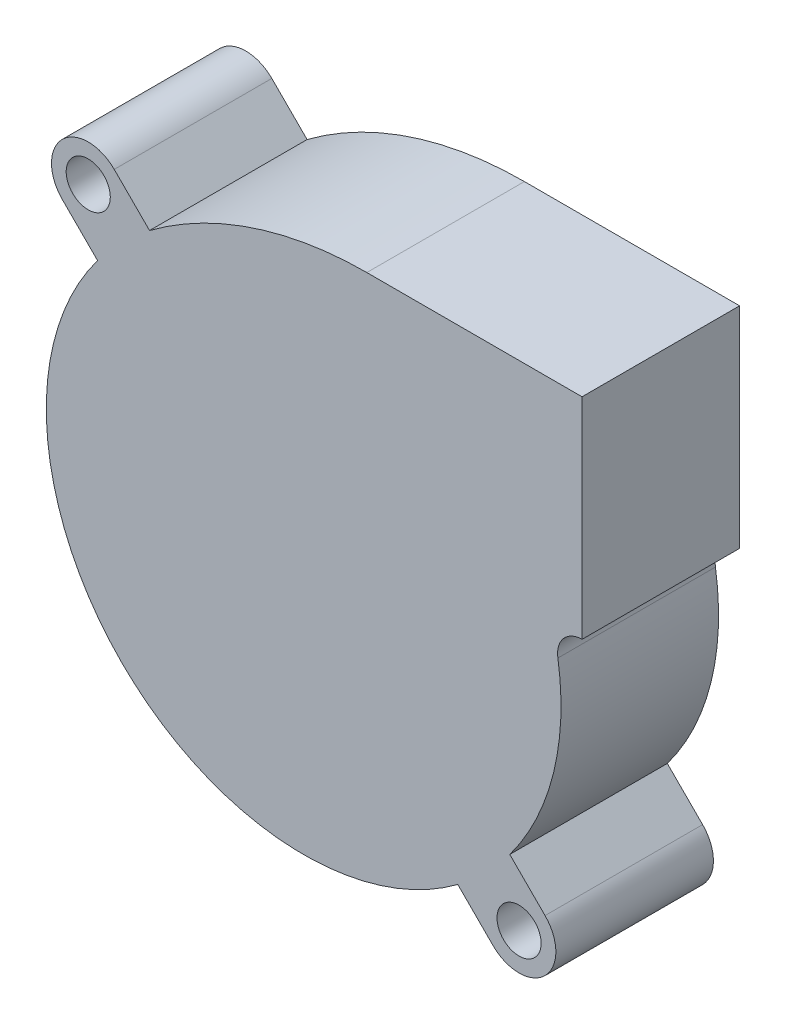
from build123d import *

# Parameters (mm, degrees)
SKETCH1_R           = 2.1
BOSS_EXTRUDE1_DEPTH = 15


with BuildPart() as part:
    # Sketch1 → Boss-Extrude1 (new body)
    with BuildSketch(Plane.XY):
        with BuildLine():
            Line((-22.980970389, 18.03122292), (-19.621301934, 14.671554465))
            ThreePointArc((-19.621301934, 14.671554465), (-17.324116139, -17.324116139), (14.671554465, -19.621301934))
            Line((14.671554465, -19.621301934), (18.03122292, -22.980970389))
            ThreePointArc((18.03122292, -22.980970389), (22.980970389, -22.980970389), (22.980970389, -18.03122292))
            Line((22.980970389, -18.03122292), (19.621301934, -14.671554465))
            ThreePointArc((19.621301934, -14.671554465), (23.780652377, -5.893265015), (24.201713513, 3.811438449))
            ThreePointArc((24.201713513, 3.811438449), (24.731491872, 5.685176303), (26.5, 6.5))
            Line((26.5, 6.5), (26.5, 26.5))
            Line((26.5, 26.5), (6.014536774, 26.5))
            ThreePointArc((6.014536774, 26.5), (-4.885358384, 24.735246981), (-14.671554465, 19.621301934))
            Line((-14.671554465, 19.621301934), (-18.03122292, 22.980970389))
            ThreePointArc((-18.03122292, 22.980970389), (-22.980970389, 22.980970389), (-22.980970389, 18.03122292))
        make_face()
        with Locations((-20.506096654, 20.506096654)):
            Circle(SKETCH1_R, mode=Mode.SUBTRACT)
        with Locations((20.506096654, -20.506096654)):
            Circle(SKETCH1_R, mode=Mode.SUBTRACT)
    extrude(amount=BOSS_EXTRUDE1_DEPTH)


solid = part.part
